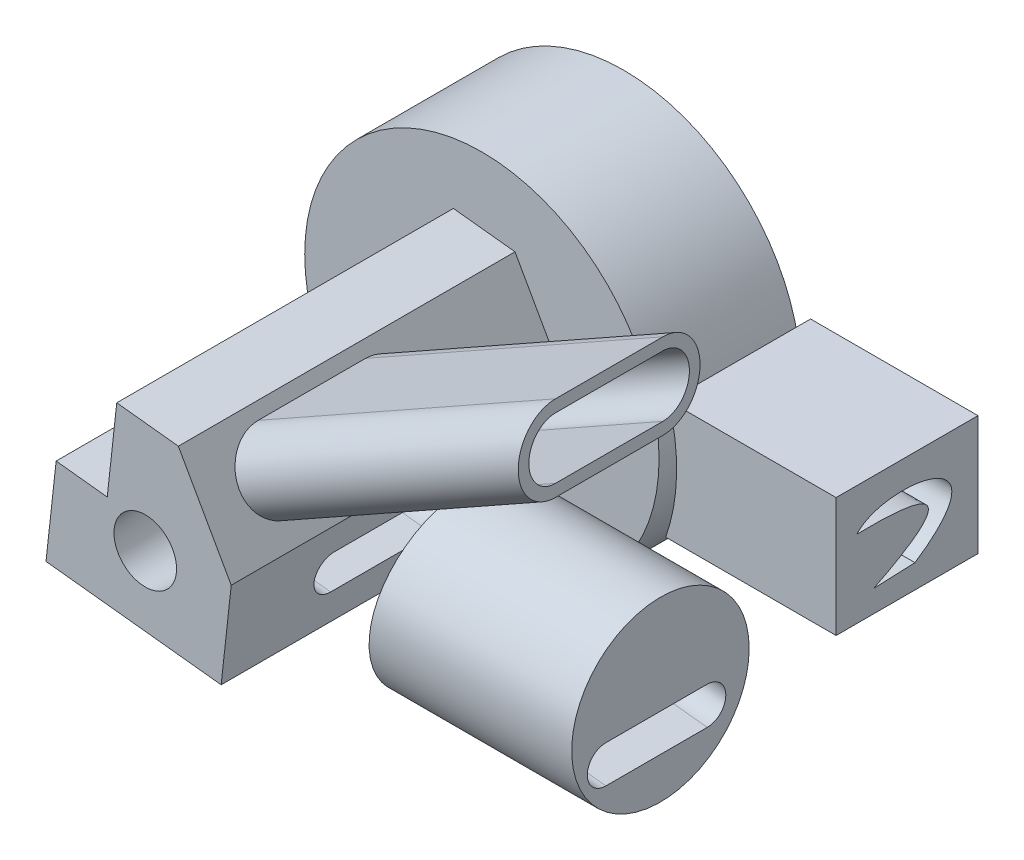
from build123d import *

# Parameters (mm, degrees)
SKETCH1_R                = 50
BOSS_EXTRUDE2_DEPTH      = 40
BOSS_EXTRUDE3_REACH      = 165.095
BOSS_EXTRUDE3_END_RADIUS = 55
SKETCH2_W                = 40.04499053
SKETCH2_H                = 33.720544817
BOSS_EXTRUDE7_DEPTH      = 95
SKETCH5_R                = 8.834953529
CUT_EXTRUDE1_DEPTH       = 176.28548143
CUT_EXTRUDE1_DRAFT       = 3
CUT_EXTRUDE2_REACH       = 209.906
EXTRUDE_THIN2_REACH      = 170.449
SKETCH8_RX               = 5.291595296
SKETCH8_RY               = 2.766061177
CUT_EXTRUDE3_DEPTH       = 170.094286938
CUT_EXTRUDE3_TAPER       = -7
BOSS_EXTRUDE9_REACH      = 217.04
SKETCH9_R                = 25.043066537
CUT_EXTRUDE5_DEPTH       = 49
CUT_EXTRUDE5_DEPTH_BACK  = 71


with BuildPart() as part:
    # Sketch1 → Boss-Extrude2 (new body)
    with BuildSketch(Plane.XY):
        Circle(SKETCH1_R)
    extrude(amount=BOSS_EXTRUDE2_DEPTH)

    # Sketch3 → Boss-Extrude7 (add)
    with BuildSketch(Plane.XY.offset(40)):
        Polygon((-10.728640002, 7.791130043), (-8.044374327, 32.168001855), (9.334208951, 30.25435457), (24.256552807, 3.732744672), (21.419333288, -22.033161115), (-28.010561318, -16.590175221), (-25.150931808, 9.379244513), align=None)
    extrude(amount=BOSS_EXTRUDE7_DEPTH)


with BuildPart() as body_2:
    # Boss-Extrude3: up to this cylinder (the profile starts outside it)
    boss_extrude3_end = Plane(origin=(0, 0, 20.022495), z_dir=(0, 0, -1)) * Cylinder(BOSS_EXTRUDE3_END_RADIUS, 441.19, mode=Mode.PRIVATE)
    # Sketch2 → Boss-Extrude3 (new, up to the surface)
    with BuildSketch(Plane(origin=(100, 0, 0), x_dir=(0, 0, -1), z_dir=(1, 0, 0)), mode=Mode.PRIVATE) as boss_extrude3_sk1:
        with Locations((-20.022495265, -1.311354521)):
            Rectangle(SKETCH2_W, SKETCH2_H)
    boss_extrude3_tool1 = extrude(boss_extrude3_sk1.sketch, amount=-BOSS_EXTRUDE3_REACH, mode=Mode.PRIVATE) - boss_extrude3_end
    add(boss_extrude3_tool1.solids().sort_by_distance((100, -1.311355, 20.022495))[0])


with BuildPart() as cut_extrude1_tool:
    # Sketch5 → Cut-Extrude1 (with draft: the straight prism first)
    with BuildSketch(Plane.XY.offset(135)):
        Circle(SKETCH5_R)
    extrude(amount=-CUT_EXTRUDE1_DEPTH)
    # Cut-Extrude1: the draft: its side faces are tilted about the plane it starts from
    cut_extrude1_sides = [cut_extrude1_tool.faces().sort_by_distance(p)[0] for p in [
        (-8.834953529, 0, 46.857259285),
    ]]
    draft(cut_extrude1_sides, Plane.XY.offset(135), CUT_EXTRUDE1_DRAFT)


with BuildPart() as part_1:
    add(part.part)

    # Cut-Extrude1: cut by cut_extrude1_tool
    add(cut_extrude1_tool.part, mode=Mode.SUBTRACT)


with BuildPart() as cut_extrude2_tool:
    # Cut-Extrude2: up to this cone (the profile starts outside it)
    cut_extrude2_end = Plane(origin=(0, 0, 23.630156), z_dir=(0, 0, -1)) * Cone(2.875782564, 26.4674169, 450.155199464, mode=Mode.PRIVATE)
    # Sketch6 → Cut-Extrude2 (new, up to the surface)
    with BuildSketch(Plane(origin=(100, 0, 0), x_dir=(0, 0, -1), z_dir=(1, 0, 0)), mode=Mode.PRIVATE) as cut_extrude2_sk1:
        with BuildLine():
            Line((-29.438403775, -11.963817818), (-17.794672623, -11.487619144))
            add(Edge.make_bspline(
                [(-34.174557394, 3.653337615), (-26.469822393, 12.611255552), (10.248205077, 7.184729327), (-17.794672623, -11.487619144)],
                knots=[0, 0, 0, 0, 1, 1, 1, 1], degree=3))
            add(Edge.make_bspline(
                [(-29.438403775, -11.963817818), (3.65750213, 4.537558968), (-34.174557394, 3.653337615)],
                knots=[0, 0, 0, 1, 1, 1], degree=2))
        make_face()
    cut_extrude2_tool1 = extrude(cut_extrude2_sk1.sketch, amount=-CUT_EXTRUDE2_REACH, mode=Mode.PRIVATE) - cut_extrude2_end
    add(cut_extrude2_tool1.solids().sort_by_distance((100, -11.392756, 23.630156))[0])


with BuildPart() as part_2:
    add(part_1.part)

    # Cut-Extrude2: cut by cut_extrude2_tool
    add(cut_extrude2_tool.part, mode=Mode.SUBTRACT)

    # Extrude-Thin2: up to this plane
    extrude_thin2_end = Plane(origin=(95, 0, 0), z_dir=(1, 0, 0))
    # Sketch7 → Extrude-Thin2 (add, up to the surface)
    with BuildSketch(Plane(origin=(20.019223712, 11.263786064, 0), x_dir=(0, 0, -1), z_dir=(0.8715202325264406, 0.49035954594262665, 0)), mode=Mode.PRIVATE) as extrude_thin2_sk1:
        with BuildLine():
            Line((-83.946439535, -2.85202549), (-114.242512364, -2.85202549))
            ThreePointArc((-114.242512364, -2.85202549), (-124.744397064, 7.64985921), (-114.242512364, 18.15174391))
            Line((-114.242512364, 18.15174391), (-83.946439535, 18.15174391))
            ThreePointArc((-83.946439535, 18.15174391), (-73.444554835, 7.64985921), (-83.946439535, -2.85202549))
        make_face()
        with BuildLine():
            Line((-83.946439535, 0.14797451), (-114.242512364, 0.14797451))
            ThreePointArc((-114.242512364, 0.14797451), (-121.744397064, 7.64985921), (-114.242512364, 15.15174391))
            Line((-114.242512364, 15.15174391), (-83.946439535, 15.15174391))
            ThreePointArc((-83.946439535, 15.15174391), (-76.444554835, 7.64985921), (-83.946439535, 0.14797451))
        make_face(mode=Mode.SUBTRACT)
    extrude_thin2_tool1 = split(extrude(extrude_thin2_sk1.sketch, amount=EXTRUDE_THIN2_REACH, mode=Mode.PRIVATE), bisect_by=extrude_thin2_end, keep=Keep.BOTH, mode=Mode.PRIVATE)
    add(extrude_thin2_tool1.solids().sort_by_distance((16.268042, 17.930793, 124.190066))[0])

    # Sketch8 → Cut-Extrude3 (cut, through all)
    with BuildSketch(Plane(origin=(20.019223712, 11.263786064, 0), x_dir=(0, 0, -1), z_dir=(0.8715202325264406, 0.49035954594262665, 0))):
        with Locations((-100.935459327, 7.917390778)):
            Ellipse(SKETCH8_RX, SKETCH8_RY)
    extrude(amount=-CUT_EXTRUDE3_DEPTH, taper=CUT_EXTRUDE3_TAPER, mode=Mode.SUBTRACT)


with BuildPart() as body_2_1:
    add(body_2.part)

    # Cut-Extrude2: cut by cut_extrude2_tool
    add(cut_extrude2_tool.part, mode=Mode.SUBTRACT)


with BuildPart() as body_3:
    # Boss-Extrude9: up to this plane
    boss_extrude9_end = Plane(origin=(43.439686672, -4.783372566, 135), z_dir=(0.9939918972973696, -0.10945368019018613, 0))
    # Sketch9 → Boss-Extrude9 (new, up to the surface)
    with BuildSketch(Plane(origin=(100, 0, 0), x_dir=(0, 0, -1), z_dir=(1, 0, 0)), mode=Mode.PRIVATE) as boss_extrude9_sk1:
        with Locations((-89.617927655, -9.047003394)):
            Circle(SKETCH9_R)
    boss_extrude9_tool1 = split(extrude(boss_extrude9_sk1.sketch, amount=-BOSS_EXTRUDE9_REACH, mode=Mode.PRIVATE), bisect_by=boss_extrude9_end, keep=Keep.BOTH, mode=Mode.PRIVATE)
    add(boss_extrude9_tool1.solids().sort_by_distance((100, -9.047003, 89.617928))[0])


with BuildPart() as cut_extrude5_tool:
    # Sketch10 → Cut-Extrude5 (new, two sides)
    with BuildSketch(Plane(origin=(43.439686672, -4.783372566, 0), x_dir=(0, 0, 1), z_dir=(-0.9939918972973696, 0.10945368019018613, 0))) as cut_extrude5_sk:
        with BuildLine():
            Line((76.418606715, -0.862508444), (105.010610596, -0.862508444))
            ThreePointArc((105.010610596, -0.862508444), (110.25684984, -6.108747688), (105.010610596, -11.354986932))
            Line((105.010610596, -11.354986932), (76.418606715, -11.354986932))
            ThreePointArc((76.418606715, -11.354986932), (71.172367471, -6.108747688), (76.418606715, -0.862508444))
        make_face()
    extrude(amount=CUT_EXTRUDE5_DEPTH)
    extrude(cut_extrude5_sk.sketch, amount=-CUT_EXTRUDE5_DEPTH_BACK)


with BuildPart() as part_3:
    add(part_2.part)

    # Cut-Extrude5: cut by cut_extrude5_tool
    add(cut_extrude5_tool.part, mode=Mode.SUBTRACT)


with BuildPart() as body_3_1:
    add(body_3.part)

    # Cut-Extrude5: cut by cut_extrude5_tool
    add(cut_extrude5_tool.part, mode=Mode.SUBTRACT)


solid = Compound([body_2_1.part, part_3.part, body_3_1.part])
